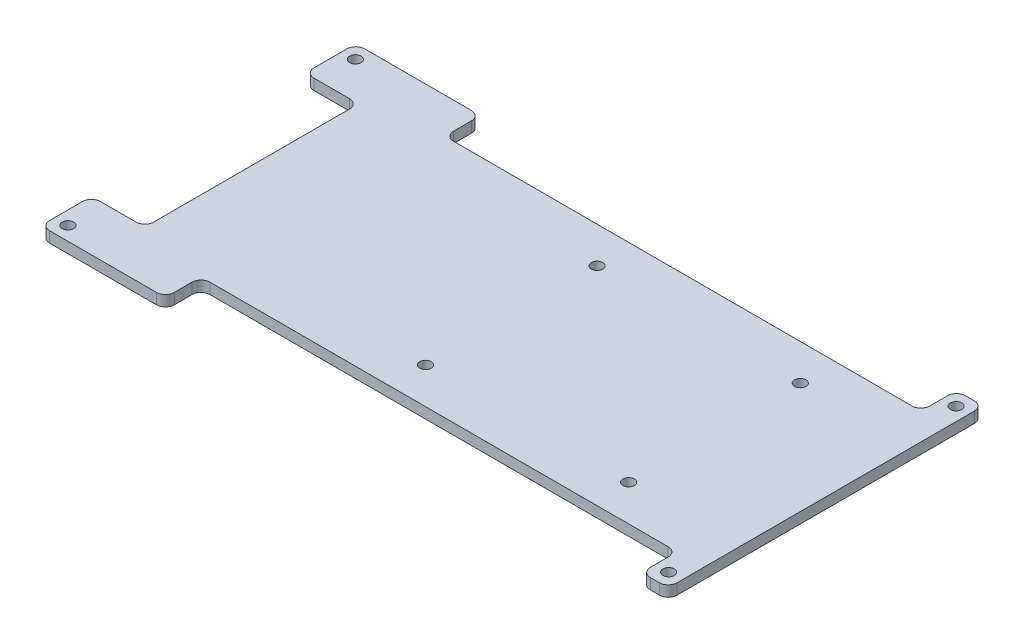
from build123d import *

# Parameters (mm, degrees)
SKETCH1_W                    = 179.07
SKETCH1_H                    = 89.916
BOSS_EXTRUDE1_DEPTH          = 3.0734
F_30_0_1285_DIAMETER_HOLE1_D = 3.2639
F_30_0_1285_DIAMETER_HOLE2_D = 3.2639
SKETCH6_W                    = 15.24
SKETCH6_H                    = 60.96
SKETCH6_W_2                  = 135.89
SKETCH6_H_2                  = 10.16
CUT_EXTRUDE1_DEPTH           = 4.0734
FILLET2_R                    = 2.54


with BuildPart() as part:
    # Sketch1 → Boss-Extrude1 (new body)
    with BuildSketch(Plane(origin=(0, 0, 0), x_dir=(1, 0, 0), z_dir=(0, 1, 0))):
        Rectangle(SKETCH1_W, SKETCH1_H)
    extrude(amount=BOSS_EXTRUDE1_DEPTH)

    # #30 (0.1285) Diameter Hole1 (through all)
    with Locations(Plane(origin=(0, 3.0734, 0), x_dir=(1, 0, 0), z_dir=(0, 1, 0))):
        with Locations((-85.725, 41.021), (-85.725, -41.021), (85.725, -41.021), (85.725, 41.021)):
            Hole(F_30_0_1285_DIAMETER_HOLE1_D / 2)

    # #30 (0.1285) Diameter Hole2 (through all)
    with Locations(Plane(origin=(0, 3.0734, 0), x_dir=(1, 0, 0), z_dir=(0, 1, 0))):
        with Locations((-0.215, 24.5), (-0.215, -24.5), (57.785, -24.5), (57.785, 24.5)):
            Hole(F_30_0_1285_DIAMETER_HOLE2_D / 2)

    # Sketch6 → Cut-Extrude1 (cut, through all)
    with BuildSketch(Plane(origin=(0, 3.0734, 0), x_dir=(1, 0, 0), z_dir=(0, 1, 0))):
        with Locations((-81.915, 0)):
            Rectangle(SKETCH6_W, SKETCH6_H)
        with Locations((13.97, -39.878)):
            Rectangle(SKETCH6_W_2, SKETCH6_H_2)
        with Locations((13.97, 39.878)):
            Rectangle(SKETCH6_W_2, SKETCH6_H_2)
    extrude(amount=-CUT_EXTRUDE1_DEPTH, mode=Mode.SUBTRACT)

    # Fillet2
    fillet2_edges = [part.edges().sort_by_distance(p)[0] for p in [
        (-89.535, 1.5367, 30.48),
        (-89.535, 1.5367, -30.48),
        (-74.295, 1.5367, -30.48),
        (-74.295, 1.5367, 30.48),
        (-89.535, 1.5367, -44.958),
        (89.535, 1.5367, -44.958),
        (89.535, 1.5367, 44.958),
        (-89.535, 1.5367, 44.958),
        (-53.975, 1.5367, 44.958),
        (-53.975, 1.5367, 34.798),
        (81.915, 1.5367, 34.798),
        (81.915, 1.5367, 44.958),
        (-53.975, 1.5367, -34.798),
        (-53.975, 1.5367, -44.958),
        (81.915, 1.5367, -44.958),
        (81.915, 1.5367, -34.798),
    ]]
    fillet(fillet2_edges, radius=FILLET2_R)


solid = part.part
